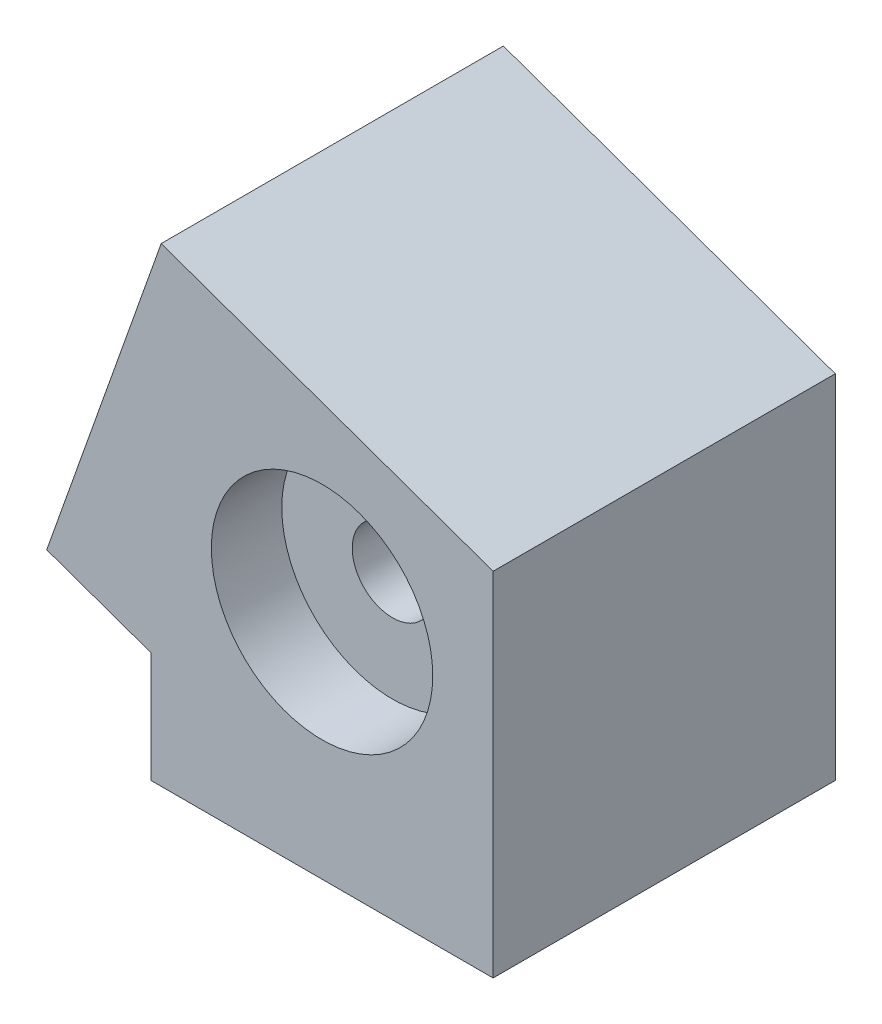
from build123d import *

# Parameters (mm, degrees)
SKETCH2_W           = 34
SKETCH2_H           = 34
BOSS_EXTRUDE2_DEPTH = 35
CUT_EXTRUDE6_DEPTH  = 35
SKETCH17_W          = 30
SKETCH17_H          = 30
CUT_EXTRUDE7_DEPTH  = 10
SKETCH18_W          = 30
SKETCH18_H          = 10
CUT_EXTRUDE8_DEPTH  = 30
SKETCH19_R          = 11
CUT_EXTRUDE10_DEPTH = 7
SKETCH20_R          = 11
CUT_EXTRUDE11_DEPTH = 7
SKETCH22_R          = 4
CUT_EXTRUDE12_DEPTH = 30


with BuildPart() as part:
    # Sketch2 → Boss-Extrude2 (new body)
    with BuildSketch(Plane(origin=(0, 0, 0), x_dir=(1, 0, 0), z_dir=(0, 1, 0))):
        Rectangle(SKETCH2_W, SKETCH2_H)
    boss_extrude2 = extrude(amount=BOSS_EXTRUDE2_DEPTH)

    # Sketch16 → Cut-Extrude6 (cut)
    with BuildSketch(Plane.XY.offset(17)):
        Polygon((-17, 35), (-17, 10.991783965), (17, 35), align=None)
    extrude(amount=-CUT_EXTRUDE6_DEPTH, mode=Mode.SUBTRACT)

    # Sketch17 → Cut-Extrude7 (cut)
    with BuildSketch(Plane.XZ):
        Rectangle(SKETCH17_W, SKETCH17_H)
    cut_extrude7 = extrude(amount=-CUT_EXTRUDE7_DEPTH, mode=Mode.SUBTRACT)

    # Mirror6: Boss-Extrude2, Cut-Extrude7 across plane
    add(boss_extrude2.mirror(Plane(origin=(17, 35, -18), x_dir=(0, 0, 1), z_dir=(0.57681494, -0.816874853, 0))))
    add(cut_extrude7.mirror(Plane(origin=(17, 35, -18), x_dir=(0, 0, 1), z_dir=(0.57681494, -0.816874853, 0))), mode=Mode.SUBTRACT)

    # Sketch18 → Cut-Extrude8 (cut)
    with BuildSketch(Plane.ZY.offset(-15)):
        with Locations((0, 5)):
            Rectangle(SKETCH18_W, SKETCH18_H)
    extrude(amount=CUT_EXTRUDE8_DEPTH, mode=Mode.SUBTRACT)

    # Sketch19 → Cut-Extrude10 (cut)
    with BuildSketch(Plane(origin=(0, 0, -17), x_dir=(-1, 0, 0), z_dir=(0, 0, -1))):
        with Locations((0, 22.995891982)):
            Circle(SKETCH19_R)
    extrude(amount=-CUT_EXTRUDE10_DEPTH, mode=Mode.SUBTRACT)

    # Sketch20 → Cut-Extrude11 (cut)
    with BuildSketch(Plane.XY.offset(17)):
        with Locations((0, 22.995891982)):
            Circle(SKETCH20_R)
    extrude(amount=-CUT_EXTRUDE11_DEPTH, mode=Mode.SUBTRACT)

    # Sketch22 → Cut-Extrude12 (cut)
    with BuildSketch(Plane.XY.offset(10)):
        with Locations((0, 22.995891982)):
            Circle(SKETCH22_R)
    extrude(amount=-CUT_EXTRUDE12_DEPTH, mode=Mode.SUBTRACT)


solid = part.part
